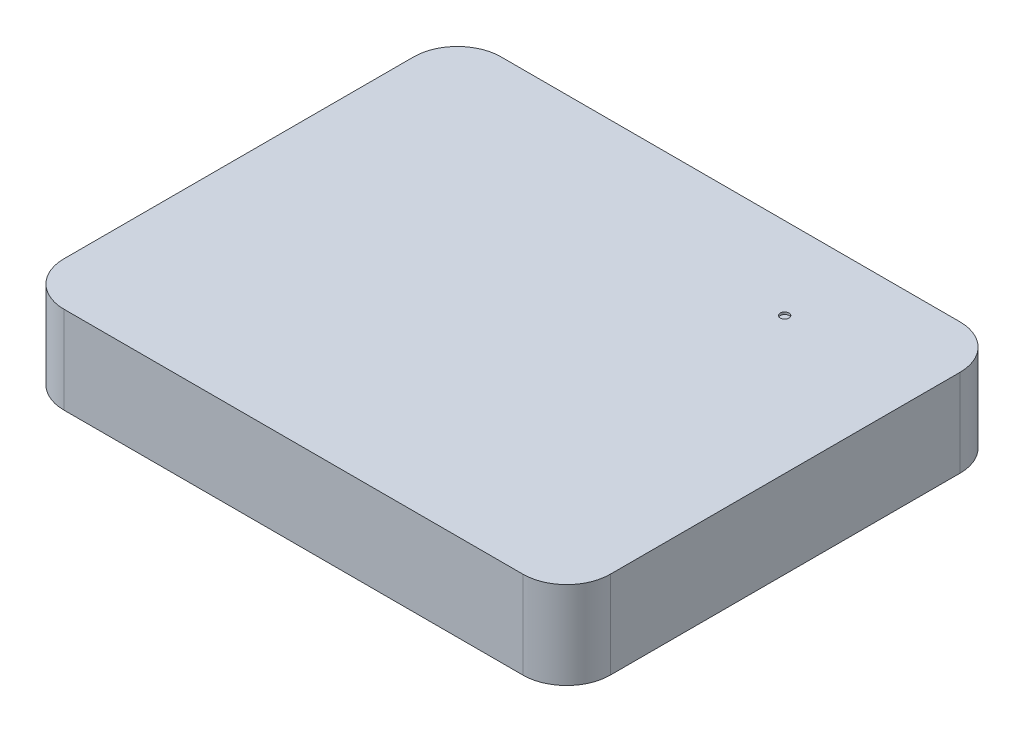
from build123d import *

# Parameters (mm, degrees)
BOSS_EXTRUDE1_DEPTH = 40
SKETCH2_R           = 2
CUT_EXTRUDE1_DEPTH  = 1


with BuildPart() as part:
    # Sketch1 → Boss-Extrude1 (new body)
    with BuildSketch(Plane(origin=(0, 0, 0), x_dir=(1, 0, 0), z_dir=(0, 1, 0))):
        with BuildLine():
            Line((105, -100), (-105, -100))
            ThreePointArc((-105, -100), (-119.142135624, -94.142135624), (-125, -80))
            Line((-125, -80), (-125, 80))
            ThreePointArc((-125, 80), (-119.142135624, 94.142135624), (-105, 100))
            Line((-105, 100), (105, 100))
            ThreePointArc((105, 100), (119.142135624, 94.142135624), (125, 80))
            Line((125, 80), (125, -80))
            ThreePointArc((125, -80), (119.142135624, -94.142135624), (105, -100))
        make_face()
    extrude(amount=BOSS_EXTRUDE1_DEPTH)

    # Sketch2 → Cut-Extrude1 (cut)
    with BuildSketch(Plane(origin=(0, 40, 0), x_dir=(1, 0, 0), z_dir=(0, 1, 0))):
        with Locations((62.367459268, 62.367459268)):
            Circle(SKETCH2_R)
    extrude(amount=-CUT_EXTRUDE1_DEPTH, mode=Mode.SUBTRACT)


solid = part.part
